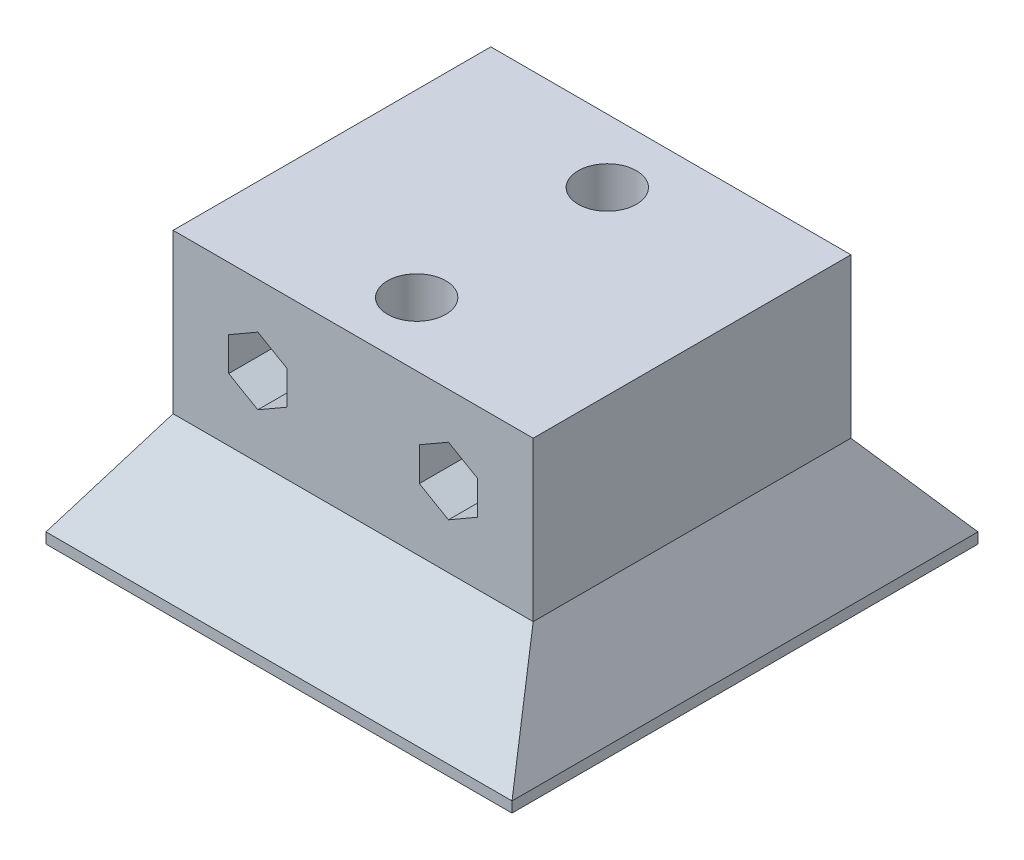
from build123d import *

# Parameters (mm, degrees)
SKETCH1_W                = 34
SKETCH1_H                = 15
BOSS_EXTRUDE1_DEPTH      = 30
BOSS_EXTRUDE2_DEPTH      = 7
BOSS_EXTRUDE2_DEPTH_BACK = 37
CUT_EXTRUDE2_DEPTH       = 38
CUT_EXTRUDE3_DEPTH       = 6
CUT_EXTRUDE3_DEPTH_BACK  = 40
SKETCH7_R                = 2.75
CUT_EXTRUDE4_DEPTH       = 25.660254038


with BuildPart() as part:
    # Sketch1 → Boss-Extrude1 (new body)
    with BuildSketch(Plane.XY):
        with Locations((17, 7.5)):
            Rectangle(SKETCH1_W, SKETCH1_H)
    extrude(amount=BOSS_EXTRUDE1_DEPTH)

    # Sketch3 → Boss-Extrude2 (add, two sides)
    with BuildSketch(Plane.XY.offset(30)) as boss_extrude2_sk:
        Polygon((0, 0), (-5, -8.660254038), (-5, -9.660254038), (39, -9.660254038), (39, -8.660254038), (34, 0), align=None)
    extrude(amount=BOSS_EXTRUDE2_DEPTH)
    extrude(boss_extrude2_sk.sketch, amount=-BOSS_EXTRUDE2_DEPTH_BACK)

    # Sketch5 → Cut-Extrude2 (cut, through all)
    with BuildSketch(Plane.XY.offset(30)):
        Polygon((8, 4.324573519), (10.75, 5.91228676), (10.75, 9.08771324), (8, 10.675426481), (5.25, 9.08771324), (5.25, 5.91228676), align=None)
        Polygon((26, 4.324573519), (28.75, 5.91228676), (28.75, 9.08771324), (26, 10.675426481), (23.25, 9.08771324), (23.25, 5.91228676), align=None)
    extrude(amount=-CUT_EXTRUDE2_DEPTH, mode=Mode.SUBTRACT)

    # Sketch6 → Cut-Extrude3 (cut, two sides)
    with BuildSketch(Plane.ZY) as cut_extrude3_sk:
        Polygon((30, 0), (37, -8.660254038), (37, 0), align=None)
        Polygon((0, 0), (-7, -8.660254038), (-7, 0), align=None)
    extrude(amount=CUT_EXTRUDE3_DEPTH, mode=Mode.SUBTRACT)
    extrude(cut_extrude3_sk.sketch, amount=-CUT_EXTRUDE3_DEPTH_BACK, mode=Mode.SUBTRACT)

    # Sketch7 → Cut-Extrude4 (cut, through all)
    with BuildSketch(Plane(origin=(0, 15, 0), x_dir=(1, 0, 0), z_dir=(0, 1, 0))):
        with Locations((17, -6)):
            Circle(SKETCH7_R)
        with Locations((17, -24)):
            Circle(SKETCH7_R)
    extrude(amount=-CUT_EXTRUDE4_DEPTH, mode=Mode.SUBTRACT)


solid = part.part
